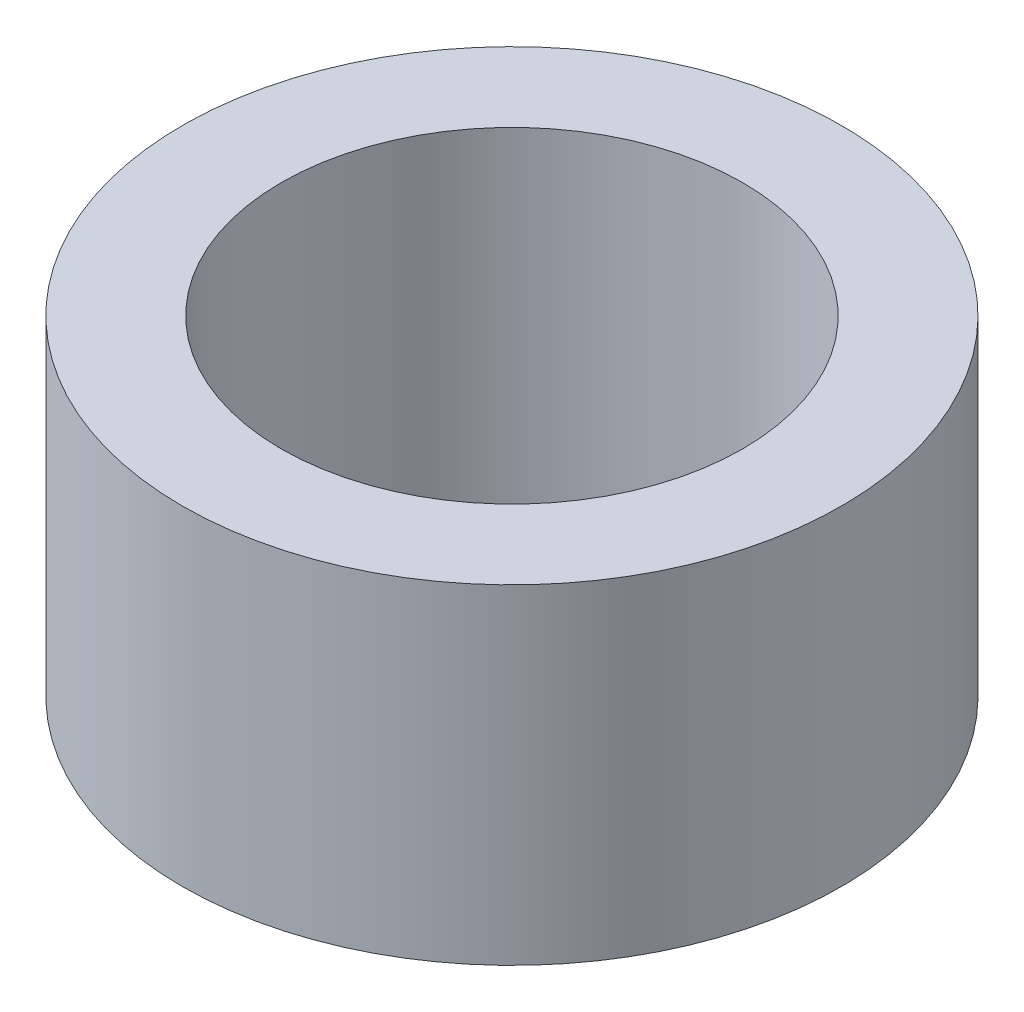
from build123d import *

# Parameters (mm, degrees)
SKETCH1_R           = 3
SKETCH1_R_2         = 2.1
BOSS_EXTRUDE1_DEPTH = 3


with BuildPart() as part:
    # Sketch1 → Boss-Extrude1 (new body)
    with BuildSketch(Plane(origin=(0, 0, 0), x_dir=(1, 0, 0), z_dir=(0, 1, 0))):
        Circle(SKETCH1_R)
        Circle(SKETCH1_R_2, mode=Mode.SUBTRACT)
    extrude(amount=BOSS_EXTRUDE1_DEPTH)


solid = part.part
